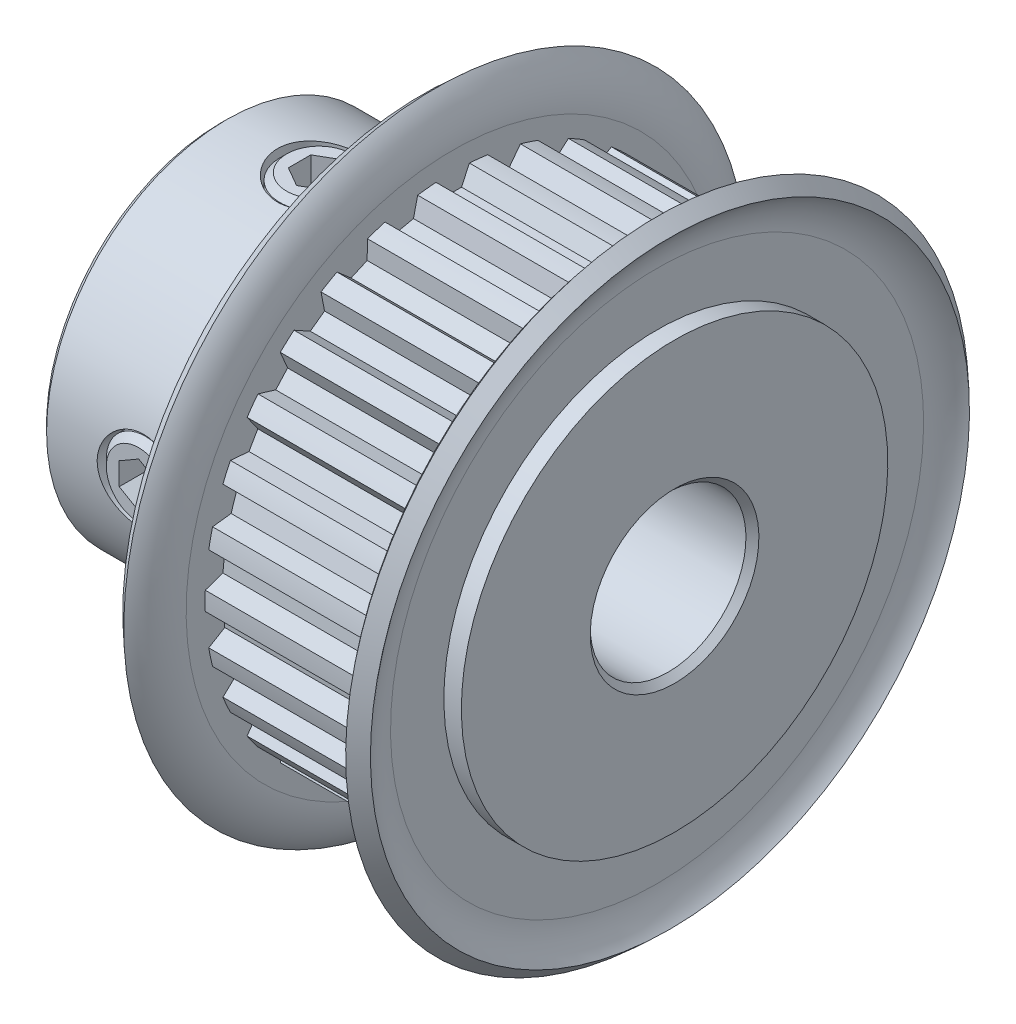
from build123d import *

# Parameters (mm, degrees)
SKETCH4_R          = 9.7
SKETCH4_R_2        = 9.54125
CUT_EXTRUDE2_DEPTH = 7.2
CUT_EXTRUDE1_DEPTH = 7.2
CIRPATTERN1_COUNT  = 30
SKETCH6_R          = 1.6
CUT_EXTRUDE3_DEPTH = 20.093519843
CUT_EXTRUDE4_DEPTH = 1.016
CIRPATTERN2_COUNT  = 2
CIRPATTERN2_ANGLE  = 90
CIRPATTERN3_COUNT  = 2
CIRPATTERN3_ANGLE  = 90
CHAMFER1_SIZE      = 0.25


with BuildPart() as part:
    # Sketch1 → Revolve1 (revolve)
    with BuildSketch(Plane.XY, mode=Mode.PRIVATE) as revolve1_sk:
        with BuildLine():
            Line((-8.75, 3), (8.75, 3))
            Line((8.75, 3), (8.75, 12))
            Line((8.75, 12), (8.075, 12))
            ThreePointArc((8.075, 12), (7.574735294, 11.199311572), (7.4, 10.2715))
            Line((7.4, 10.2715), (7.4, 9.7))
            Line((7.4, 9.7), (0.2, 9.7))
            Line((0.2, 9.7), (0.2, 10.2715))
            ThreePointArc((0.2, 10.2715), (0.025264706, 11.199311572), (-0.475, 12))
            Line((-0.475, 12), (-1.15, 12))
            Line((-1.15, 12), (-1.15, 6.95))
            Line((-1.15, 6.95), (-8.75, 6.95))
            Line((-8.75, 6.95), (-8.75, 3))
        make_face()
    revolve(revolve1_sk.sketch.rotate(Axis((-8.75, 0, 0), (1, 0, 0)), 180), axis=Axis((-8.75, 0, 0), (1, 0, 0)))

    # Sketch4 → Cut-Extrude2 (cut)
    with BuildSketch(Plane(origin=(0.2, 0, 0), x_dir=(0, 0, -1), z_dir=(1, 0, 0))):
        Circle(SKETCH4_R)
        with Locations(Location((0, 0, 0), (0, 0, 90))):
            Circle(SKETCH4_R_2, mode=Mode.SUBTRACT)
    extrude(amount=CUT_EXTRUDE2_DEPTH, mode=Mode.SUBTRACT)

    # Sketch3 → Cut-Extrude1 (cut)
    with BuildSketch(Plane(origin=(0.2, 0, 0), x_dir=(0, 0, -1), z_dir=(1, 0, 0))):
        with BuildLine():
            Line((-0.643519092, 9.519523872), (-0.339706568, 8.867995811))
            Line((-0.339706568, 8.867995811), (0.339706568, 8.867995811))
            Line((0.339706568, 8.867995811), (0.643519092, 9.519523872))
            ThreePointArc((0.643519092, 9.519523872), (0, 9.54125), (-0.643519092, 9.519523872))
        make_face()
    cut_extrude1 = extrude(amount=CUT_EXTRUDE1_DEPTH, mode=Mode.SUBTRACT)

    # CirPattern1: Cut-Extrude1 ×30 about axis
    cirpattern1_axis = Axis((0, 0, 0), (1, 0, 0))
    for i in range(1, CIRPATTERN1_COUNT):
        add(cut_extrude1.rotate(cirpattern1_axis, i * 360 / CIRPATTERN1_COUNT), mode=Mode.SUBTRACT)

    # Sketch6 → Cut-Extrude3 (cut, through all)
    with BuildSketch(Plane(origin=(0, 0, 0), x_dir=(1, 0, 0), z_dir=(0, 1, 0))):
        with Locations(Location((-4.95, 0, 0), (0, 0, 90))):
            Circle(SKETCH6_R)
    cut_extrude3 = extrude(amount=CUT_EXTRUDE3_DEPTH, mode=Mode.SUBTRACT)

    # CirPattern2: Cut-Extrude3 ×2 about axis
    cirpattern2_axis = Axis((-8.75, 0, 0), (1, 0, 0))
    for i in range(1, CIRPATTERN2_COUNT):
        add(cut_extrude3.rotate(cirpattern2_axis, i * CIRPATTERN2_ANGLE / (CIRPATTERN2_COUNT - 1)), mode=Mode.SUBTRACT)

    # Chamfer1
    chamfer1_edges = [part.edges().sort_by_distance(p)[0] for p in [
        (8.75, 3, 0),
        (-8.75, 3, 0),
        (-8.75, 6.95, 0),
    ]]
    chamfer(chamfer1_edges, length=CHAMFER1_SIZE)

    # Sketch9 → Cut-Revolve1 (revolve, cut)
    with BuildSketch(Plane.XY, mode=Mode.PRIVATE) as cut_revolve1_sk:
        with BuildLine():
            Line((8.075, 12), (8.571366975, 11.542567135))
            ThreePointArc((8.571366975, 11.542567135), (8.20349308, 10.953774108), (8.075, 10.2715))
            Line((8.075, 10.2715), (8.075, 8.21646775))
            Line((8.075, 8.21646775), (8.75, 8.21646775))
            Line((8.75, 8.21646775), (8.75, 12))
            Line((8.75, 12), (8.384992335, 12.336377137))
            Line((8.384992335, 12.336377137), (8.075, 12))
        make_face()
    cut_revolve1 = revolve(cut_revolve1_sk.sketch.rotate(Axis((-8.75, 0, 0), (1, 0, 0)), 180), axis=Axis((-8.75, 0, 0), (1, 0, 0)), mode=Mode.SUBTRACT)

    # Mirror1: Cut-Revolve1 across plane
    add(cut_revolve1.mirror(Plane(origin=(3.8, 0, 0), x_dir=(0, 0, 1), z_dir=(1, 0, 0))), mode=Mode.SUBTRACT)


with BuildPart() as body_2:
    # Sketch7 → Revolve2 (revolve)
    with BuildSketch(Plane.XY, mode=Mode.PRIVATE) as revolve2_sk:
        Polygon((-6.196, 6.95), (-4.95, 6.95), (-4.95, 3.381), (-6.196, 3.381), (-6.45, 3.635), (-6.45, 6.696), align=None)
    revolve(revolve2_sk.sketch.rotate(Axis((-4.95, 3.381, 0), (0, 1, 0)), 270), axis=Axis((-4.95, 3.381, 0), (0, 1, 0)))

    # Sketch8 → Cut-Extrude4 (cut)
    with BuildSketch(Plane(origin=(0, 6.95, 0), x_dir=(1, 0, 0), z_dir=(0, 1, 0))):
        Polygon((-4.95, 0.866025404), (-5.7, 0.433012702), (-5.7, -0.433012702), (-4.95, -0.866025404), (-4.2, -0.433012702), (-4.2, 0.433012702), align=None)
    extrude(amount=-CUT_EXTRUDE4_DEPTH, mode=Mode.SUBTRACT)


with BuildPart() as cirpattern3_1:
    # CirPattern3: pattern copy
    add(body_2.part.rotate(Axis((0, 0, 0), (1, 0, 0)), 1 * CIRPATTERN3_ANGLE / (CIRPATTERN3_COUNT - 1)))


solid = Compound([part.part, body_2.part, cirpattern3_1.part])
